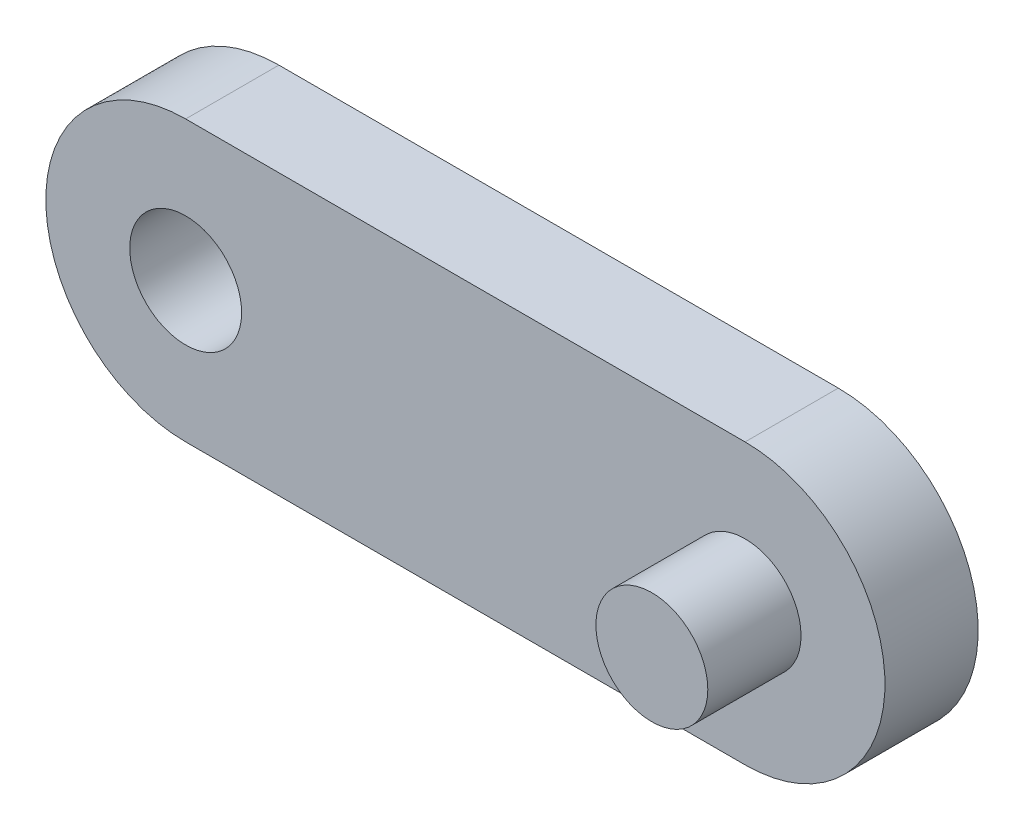
from build123d import *

# Parameters (mm, degrees)
CROQUIS1_R              = 6
SALIENTE_EXTRUIR1_DEPTH = 10
CROQUIS2_R              = 6
SALIENTE_EXTRUIR2_DEPTH = 10


with BuildPart() as part:
    # Croquis1 → Saliente-Extruir1 (new body)
    with BuildSketch(Plane.XY):
        with BuildLine():
            Line((0, 15), (60, 15))
            ThreePointArc((60, 15), (75, 0), (60, -15))
            Line((60, -15), (0, -15))
            ThreePointArc((0, -15), (-15, 0), (0, 15))
        make_face()
        Circle(CROQUIS1_R, mode=Mode.SUBTRACT)
    extrude(amount=SALIENTE_EXTRUIR1_DEPTH)

    # Croquis2 → Saliente-Extruir2 (add)
    with BuildSketch(Plane.XY.offset(10)):
        with Locations((60, 0)):
            Circle(CROQUIS2_R)
    extrude(amount=SALIENTE_EXTRUIR2_DEPTH)


solid = part.part
